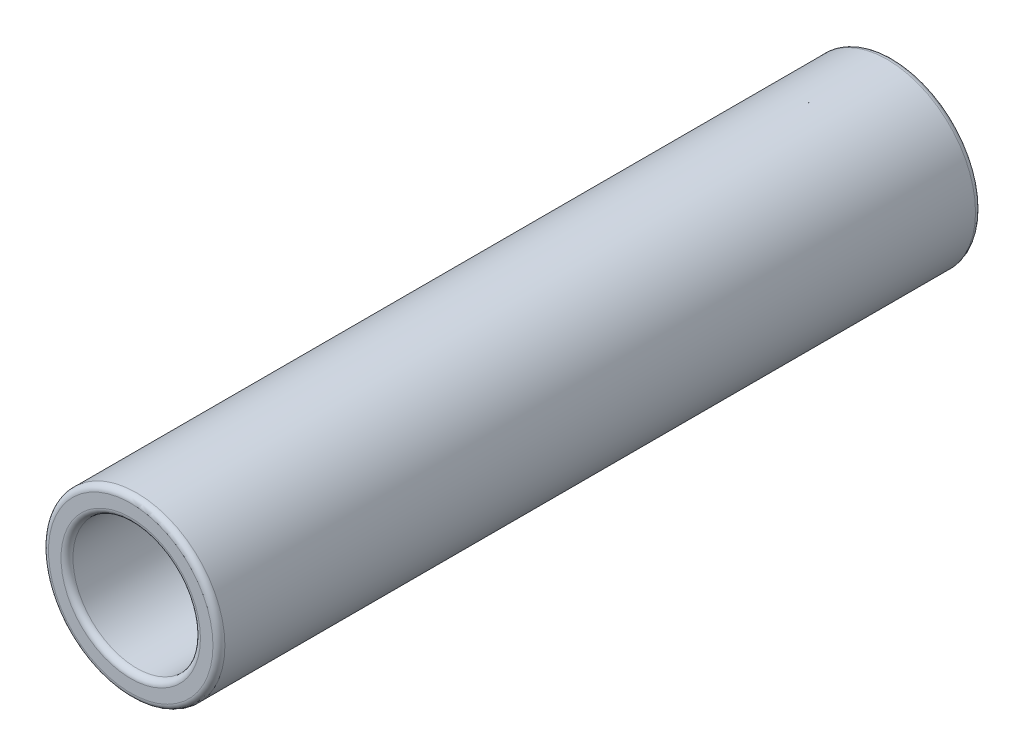
from build123d import *

# Parameters (mm, degrees)
SKETCH1_R      = 5.9
EXTRUDE1_DEPTH = 51
SKETCH2_R      = 4.263277526
EXTRUDE2_DEPTH = 52.678041759
FILLET1_R      = 0.4
SKETCH3_W      = 0.324130055
SKETCH3_H      = 0.237695373


with BuildPart() as part:
    # Sketch1 → Extrude1 (new body)
    with BuildSketch(Plane.XY):
        Circle(SKETCH1_R)
    extrude(amount=EXTRUDE1_DEPTH)

    # Sketch2 → Extrude2 (cut, through all)
    with BuildSketch(Plane.XY.offset(51)):
        Circle(SKETCH2_R)
    extrude(amount=-EXTRUDE2_DEPTH, mode=Mode.SUBTRACT)

    # Fillet1
    fillet1_edges = [part.edges().sort_by_distance(p)[0] for p in [
        (-5.9, 0, 0),
        (-5.9, 0, 51),
        (-4.263277526, 0, 0),
        (-4.263277526, 0, 51),
    ]]
    fillet(fillet1_edges, radius=FILLET1_R)

    # Cut-Sweep2: sweep along a curve in space
    with BuildLine() as cut_sweep2_path:
        ThreePointArc((4.263277526, 0, 0.4), (3.014592449, 3.014592449, 0.4), (0, 4.263277526, 0.4))
        ThreePointArc((0, 4.263277526, 0.4), (-3.014592449, 3.014592449, 0.4), (-4.263277526, 0, 0.4))
        ThreePointArc((-4.263277526, 0, 0.4), (-3.014592449, -3.014592449, 0.4), (0, -4.263277526, 0.4))
        ThreePointArc((0, -4.263277526, 0.4), (3.014592449, -3.014592449, 0.4), (4.263277526, 0, 0.4))
    # Sketch3 → Cut-Sweep2 (sweep, cut)
    with BuildSketch(Plane(origin=(0, 0, 0), x_dir=(1, 0, 0), z_dir=(0, 1, 0))):
        with Locations((-4.241785701, -0.709092592)):
            Rectangle(SKETCH3_W, SKETCH3_H)
    sweep(path=cut_sweep2_path.line, mode=Mode.SUBTRACT)


solid = part.part
